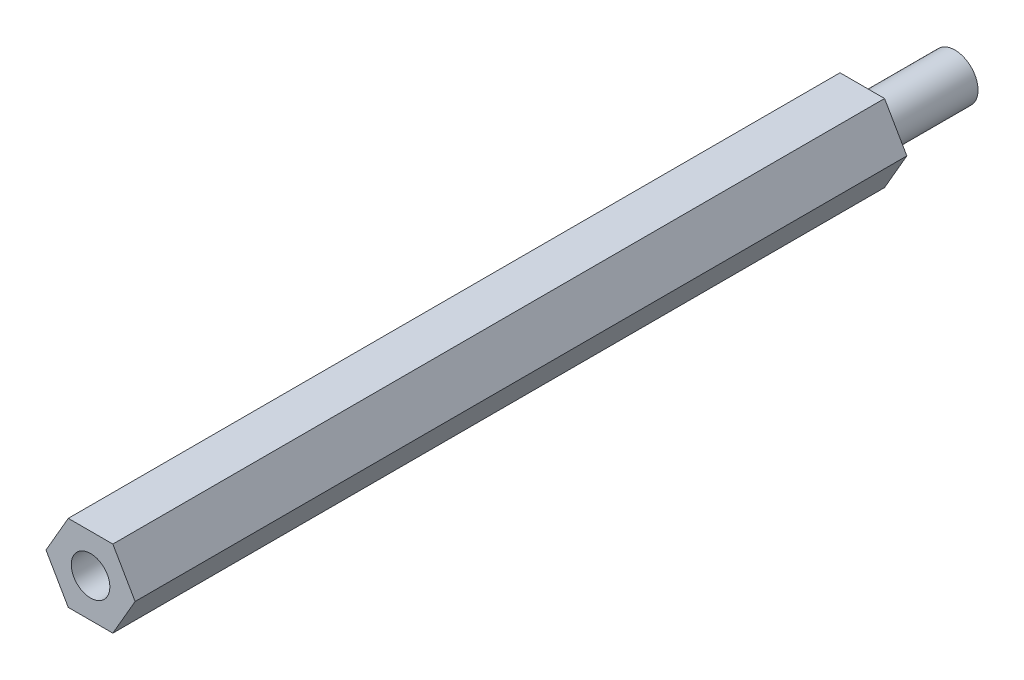
from build123d import *

# Parameters (mm, degrees)
EXTRUDE_1_DEPTH = 50
SKETCH_4_R      = 1.5
EXTRUDE_2_DEPTH = 6
M3X0_5_1_D      = 2.5
M3X0_5_1_DEPTH  = 7.5
M3X0_5_1_TIP    = 0.751075774


with BuildPart() as part:
    # 草圖1 → 填料-伸長1 (new body)
    with BuildSketch(Plane.XY):
        Polygon((-1.443375673, 2.5), (-2.886751346, 0), (-1.443375673, -2.5), (1.443375673, -2.5), (2.886751346, 0), (1.443375673, 2.5), align=None)
    extrude(amount=EXTRUDE_1_DEPTH)

    # 草圖4 → 填料-伸長2 (add)
    with BuildSketch(Plane(origin=(0, 0, 0), x_dir=(-1, 0, 0), z_dir=(0, 0, -1))):
        Circle(SKETCH_4_R)
    extrude(amount=EXTRUDE_2_DEPTH)

    # M3x0.5 螺紋孔1
    with Locations(Plane.XY.offset(50)):
        with Locations((0, 0)):
            Hole(M3X0_5_1_D / 2, depth=M3X0_5_1_DEPTH)
            with Locations((0, 0, -(M3X0_5_1_DEPTH + M3X0_5_1_TIP / 2))):  # 118° drill point
                Cone(0, M3X0_5_1_D / 2, M3X0_5_1_TIP, mode=Mode.SUBTRACT)


solid = part.part
